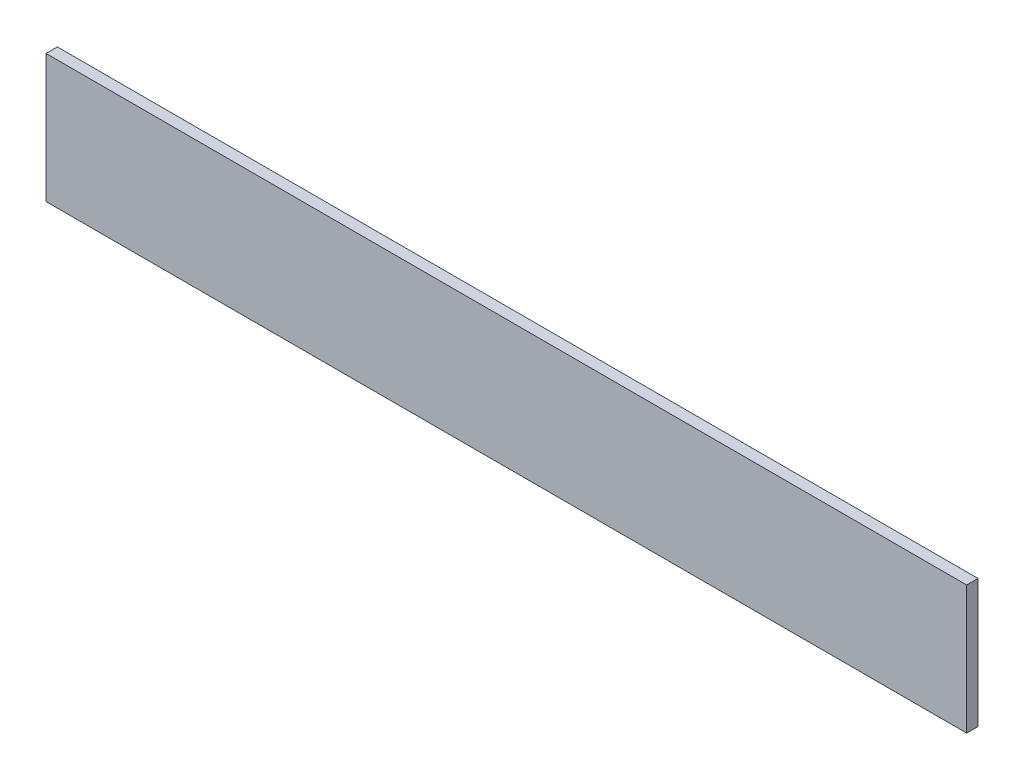
from build123d import *

# Parameters (mm, degrees)
SKETCH1_W           = 122
SKETCH1_H           = 17
BOSS_EXTRUDE1_DEPTH = 1.5


with BuildPart() as part:
    # Sketch1 → Boss-Extrude1 (new body)
    with BuildSketch(Plane.XY):
        Rectangle(SKETCH1_W, SKETCH1_H)
    extrude(amount=BOSS_EXTRUDE1_DEPTH)


solid = part.part
